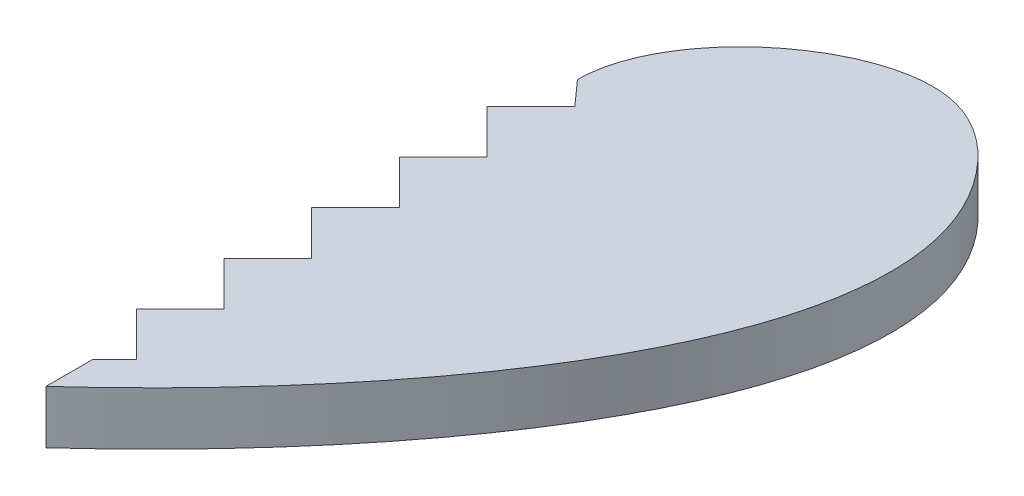
from build123d import *

# Parameters (mm, degrees)
BOSS_EXTRUDE1_DEPTH = 3
CUT_EXTRUDE1_DEPTH  = 3


with BuildPart() as part:
    # Sketch1 → Boss-Extrude1 (new body)
    with BuildSketch(Plane(origin=(0, 0, 0), x_dir=(1, 0, 0), z_dir=(0, 1, 0))):
        with BuildLine():
            add(Edge.make_bspline(
                [(0, 14.072144476), (0, 19.244859197), (9.420520606, 26.756374749), (24.913753139, 13.272155804), (11.532977672, -5.454623459), (0, -15.927855524)],
                knots=[0, 0, 0, 0, 0.261667034, 0.361667034, 1, 1, 1, 1], degree=3))
            add(Edge.make_bspline(
                [(0, 14.072144476), (0, 19.244859197), (-9.420520606, 26.756374749), (-24.913753139, 13.272155804), (-11.532977672, -5.454623459), (0, -15.927855524)],
                knots=[0, 0, 0, 0, 0.261667034, 0.361667034, 1, 1, 1, 1], degree=3))
        make_face()
    extrude(amount=BOSS_EXTRUDE1_DEPTH)

    # Sketch3 → Cut-Extrude1 (cut)
    with BuildSketch(Plane(origin=(0, 3, 0), x_dir=(1, 0, 0), z_dir=(0, 1, 0))):
        with BuildLine():
            Line((0, 14.072144476), (1.237436867, 12.683950014))
            Line((1.237436867, 12.683950014), (-1.237436867, 10.20907628))
            Line((-1.237436867, 10.20907628), (1.237436867, 7.734202545))
            Line((1.237436867, 7.734202545), (-1.237436867, 5.259328811))
            Line((-1.237436867, 5.259328811), (1.237436867, 2.784455077))
            Line((1.237436867, 2.784455077), (-1.237436867, 0.309581343))
            Line((-1.237436867, 0.309581343), (1.237436867, -2.165292391))
            Line((1.237436867, -2.165292391), (-1.237436867, -4.640166125))
            Line((-1.237436867, -4.640166125), (1.237436867, -7.11503986))
            Line((1.237436867, -7.11503986), (-1.237436867, -9.589913594))
            Line((-1.237436867, -9.589913594), (1.237436867, -12.064787328))
            Line((1.237436867, -12.064787328), (0, -13.302224195))
            Line((0, -13.302224195), (0, -15.927855524))
            add(Edge.make_bspline(
                [(0, 14.072144476), (0, 19.244859197), (-9.420520606, 26.756374749), (-24.913753139, 13.272155804), (-11.532977672, -5.454623459), (0, -15.927855524)],
                knots=[0, 0, 0, 0, 0.261667034, 0.361667034, 1, 1, 1, 1], degree=3))
        make_face()
    extrude(amount=-CUT_EXTRUDE1_DEPTH, mode=Mode.SUBTRACT)


solid = part.part
